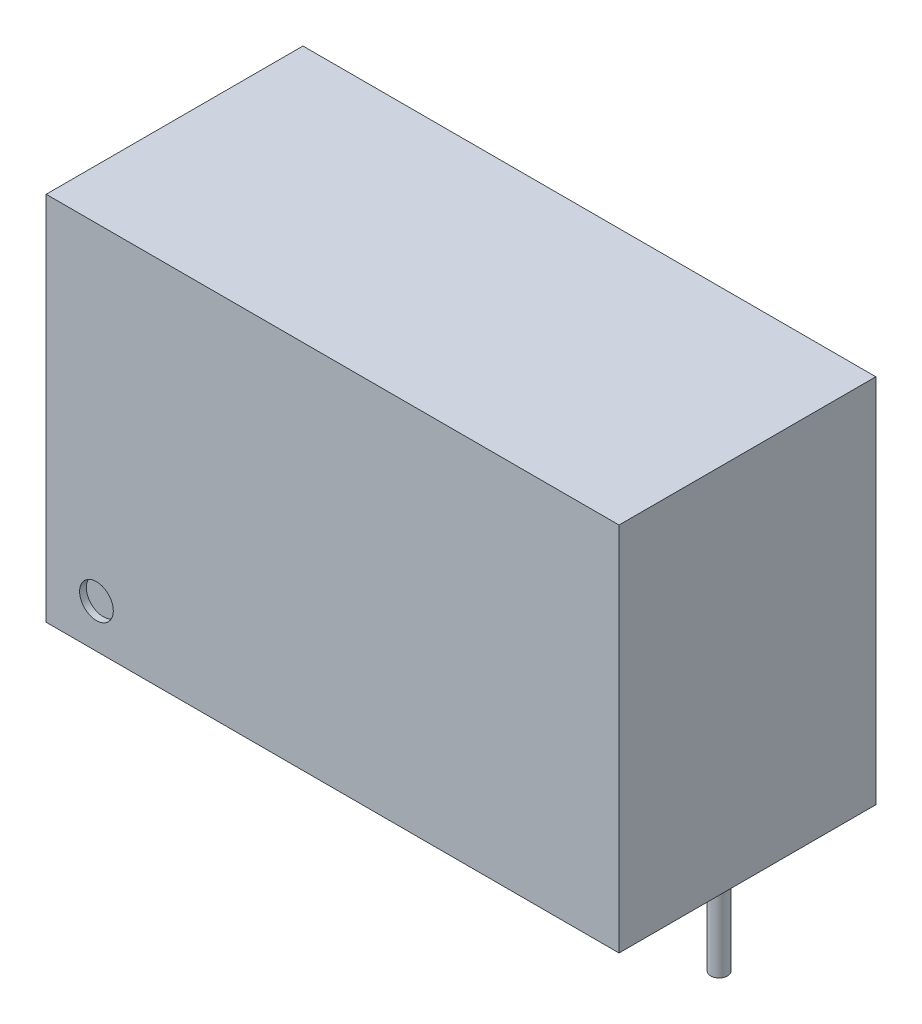
from build123d import *

# Parameters (mm, degrees)
SKETCH1_W             = 17
SKETCH1_H             = 7.62
BOSS_EXTRUDE1_DEPTH   = 11
SKETCH2_R             = 0.25
BOSS_EXTRUDE2_DEPTH   = 4.1
BOSS_EXTRUDE2_2_DEPTH = 4.1
BOSS_EXTRUDE2_3_DEPTH = 4.1
BOSS_EXTRUDE2_4_DEPTH = 4.1
BOSS_EXTRUDE2_5_DEPTH = 4.1
SKETCH3_R             = 0.5
CUT_EXTRUDE1_DEPTH    = 0.2


with BuildPart() as part:
    # Sketch1 → Boss-Extrude1 (new body)
    with BuildSketch(Plane(origin=(0, 0, 0), x_dir=(1, 0, 0), z_dir=(0, 1, 0))):
        with Locations((8.5, 3.81)):
            Rectangle(SKETCH1_W, SKETCH1_H)
    extrude(amount=BOSS_EXTRUDE1_DEPTH)

    # Sketch3 → Cut-Extrude1 (cut)
    with BuildSketch(Plane.XY):
        with Locations((1.492027109, 1.289577557)):
            Circle(SKETCH3_R)
    extrude(amount=-CUT_EXTRUDE1_DEPTH, mode=Mode.SUBTRACT)


with BuildPart() as body_2:
    # Sketch2 → Boss-Extrude2 (new body)
    with BuildSketch(Plane.XZ):
        with Locations((2.15, -5.12)):
            Circle(SKETCH2_R)
    extrude(amount=BOSS_EXTRUDE2_DEPTH)


with BuildPart() as body_3:
    # Sketch2 → Boss-Extrude2 2 (new body)
    with BuildSketch(Plane.XZ):
        with Locations((4.69, -5.12)):
            Circle(SKETCH2_R)
    extrude(amount=BOSS_EXTRUDE2_2_DEPTH)


with BuildPart() as body_4:
    # Sketch2 → Boss-Extrude2 3 (new body)
    with BuildSketch(Plane.XZ):
        with Locations((9.77, -5.12)):
            Circle(SKETCH2_R)
    extrude(amount=BOSS_EXTRUDE2_3_DEPTH)


with BuildPart() as body_5:
    # Sketch2 → Boss-Extrude2 4 (new body)
    with BuildSketch(Plane.XZ):
        with Locations((12.31, -5.12)):
            Circle(SKETCH2_R)
    extrude(amount=BOSS_EXTRUDE2_4_DEPTH)


with BuildPart() as body_6:
    # Sketch2 → Boss-Extrude2 5 (new body)
    with BuildSketch(Plane.XZ):
        with Locations((14.85, -5.12)):
            Circle(SKETCH2_R)
    extrude(amount=BOSS_EXTRUDE2_5_DEPTH)


solid = Compound([part.part, body_2.part, body_3.part, body_4.part, body_5.part, body_6.part])
